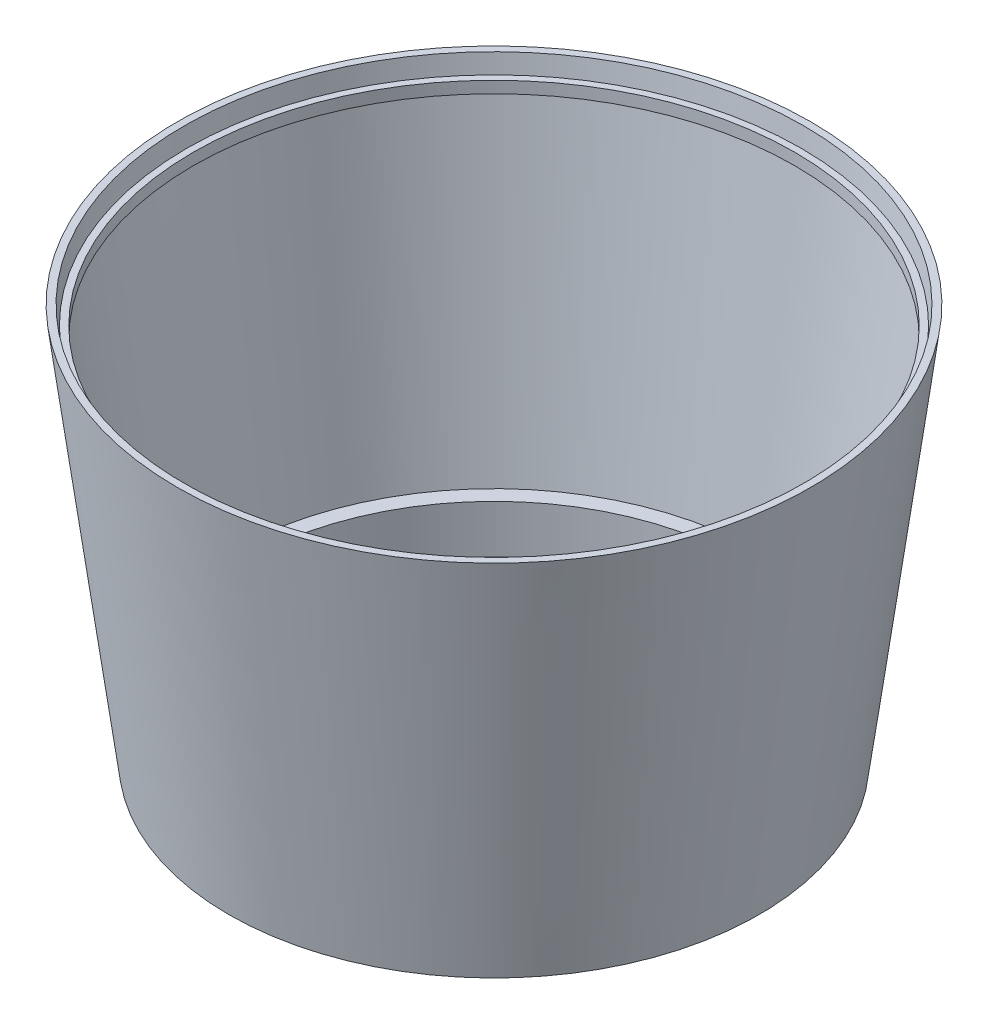
from build123d import *


with BuildPart() as part:
    # 草图1 → 旋转1 (revolve)
    with BuildSketch(Plane.XY):
        Polygon((6.378607461, 4.52446175), (50.555534049, 4.52446175), (206.193155346, 1201.513865742), (184.967848601, 1201.513865742), (177.739311305, 1145.920092987), (157.741549268, 1145.920092987), (157.741549268, 1110.553367049), (178.314621, 1110.553367049), (53.388370999, 149.761263662), (6.378607461, 149.761263662), align=None)
    revolve(axis=Axis((-752, 4.52446175, 0), (0, 1, 0)))


solid = part.part
